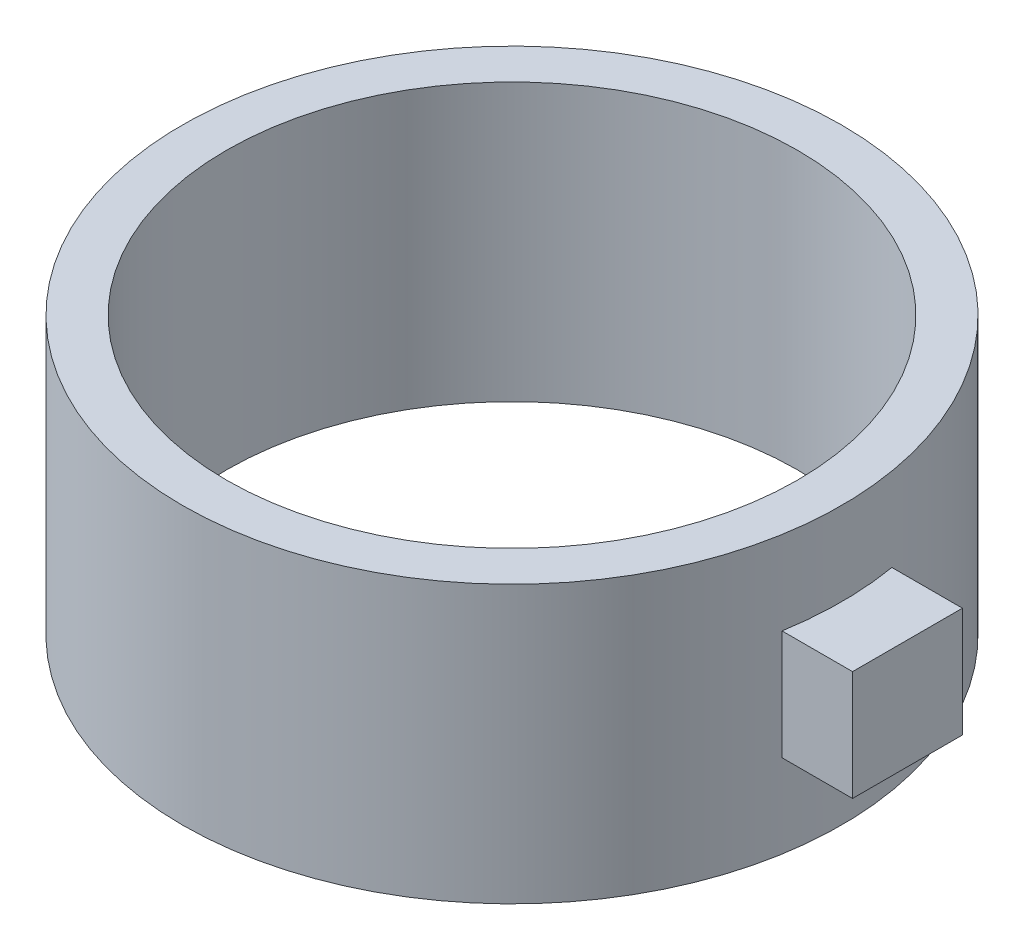
from build123d import *

# Parameters (mm, degrees)
SKETCH1_R                = 15
SKETCH1_R_2              = 13
BOSS_EXTRUDE2_DEPTH      = 12.6
BOSS_EXTRUDE3_DEPTH      = 3
BOSS_EXTRUDE3_DEPTH_BACK = 1


with BuildPart() as part:
    # Sketch1 → Boss-Extrude2 (new body)
    with BuildSketch(Plane(origin=(0, 0, 0), x_dir=(1, 0, 0), z_dir=(0, 1, 0))):
        with Locations((2.543609681, -2.543609681)):
            Circle(SKETCH1_R)
        with Locations((2.543609681, -2.543609681)):
            Circle(SKETCH1_R_2, mode=Mode.SUBTRACT)
    extrude(amount=BOSS_EXTRUDE2_DEPTH)

    # Sketch3 → Boss-Extrude3 (add, two sides)
    with BuildSketch(Plane(origin=(17.543609681, 0, 0), x_dir=(0, 0, -1), z_dir=(1, 0, 0))) as boss_extrude3_sk:
        Polygon((-5.043609681, 6.3), (-5.043609681, 8.8), (-0.043609681, 8.8), (-0.043609681, 6.3), (-0.043609681, 3.8), (-5.043609681, 3.8), align=None)
    extrude(amount=BOSS_EXTRUDE3_DEPTH)
    extrude(boss_extrude3_sk.sketch, amount=-BOSS_EXTRUDE3_DEPTH_BACK)


solid = part.part
